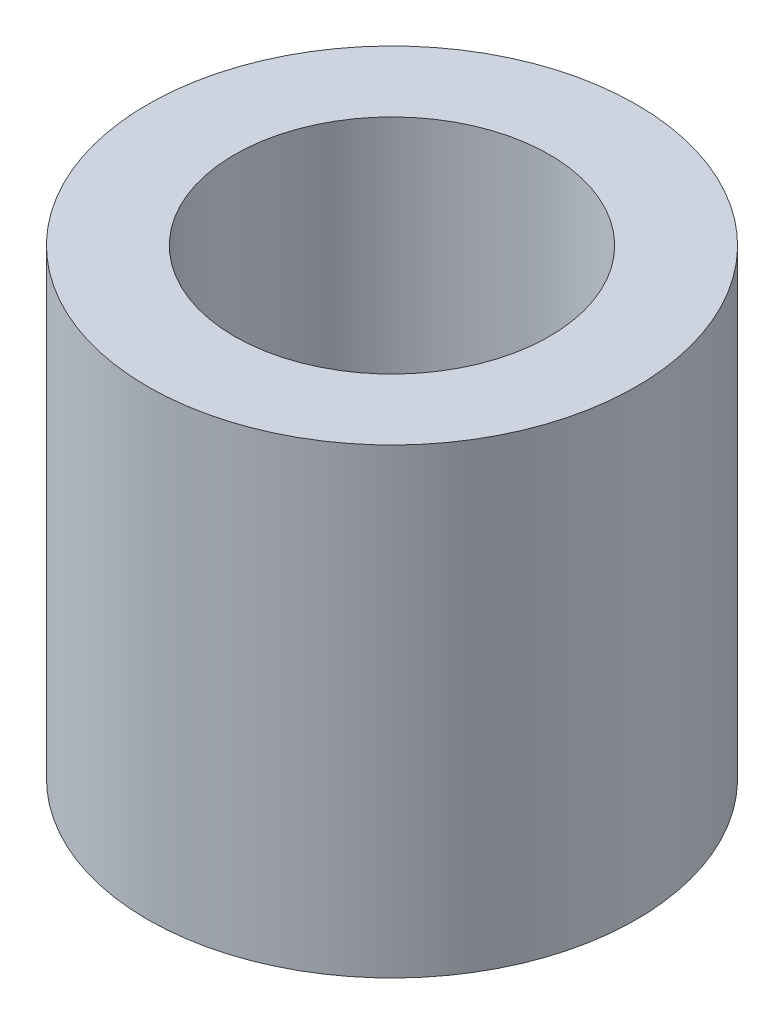
from build123d import *

# Parameters (mm, degrees)
SKETCH1_R              = 2.25
BOSS_EXTRUDE1_DEPTH    = 4.25
M2_5_CLEARANCE_HOLE1_D = 2.9


with BuildPart() as part:
    # Sketch1 → Boss-Extrude1 (new body)
    with BuildSketch(Plane(origin=(0, 0, 0), x_dir=(1, 0, 0), z_dir=(0, 1, 0))):
        Circle(SKETCH1_R)
    extrude(amount=BOSS_EXTRUDE1_DEPTH)

    # M2.5 Clearance Hole1 (through all)
    with Locations(Plane(origin=(0, 4.25, 0), x_dir=(1, 0, 0), z_dir=(0, 1, 0))):
        with Locations((0, 0)):
            Hole(M2_5_CLEARANCE_HOLE1_D / 2)


solid = part.part
